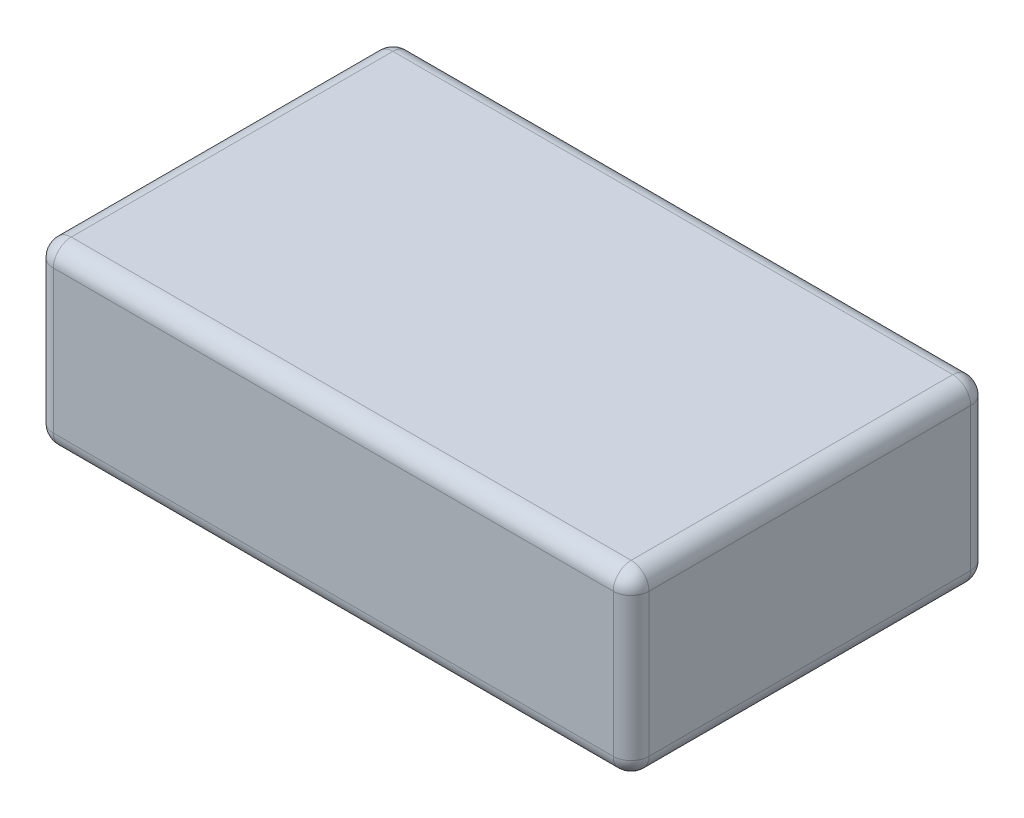
from build123d import *

# Parameters (mm, degrees)
SKETCH_1_W      = 100
SKETCH_1_H      = 60
EXTRUDE_1_DEPTH = 30
FILLET_1_R      = 3


with BuildPart() as part:
    # Эскиз1 → Бобышка-Вытянуть1 (new body)
    with BuildSketch(Plane(origin=(0, 0, 0), x_dir=(1, 0, 0), z_dir=(0, 1, 0))):
        Rectangle(SKETCH_1_W, SKETCH_1_H)
    extrude(amount=EXTRUDE_1_DEPTH)

    # Скругление1
    fillet_1_edges = [part.edges().sort_by_distance(p)[0] for p in [
        (-50, 30, 0),
        (0, 30, 30),
        (50, 30, 0),
        (0, 0, 30),
        (-50, 0, 0),
        (0, 0, -30),
        (50, 0, 0),
        (50, 15, 30),
        (-50, 15, 30),
        (-50, 15, -30),
        (50, 15, -30),
        (0, 30, -30),
    ]]
    fillet(fillet_1_edges, radius=FILLET_1_R)


solid = part.part
